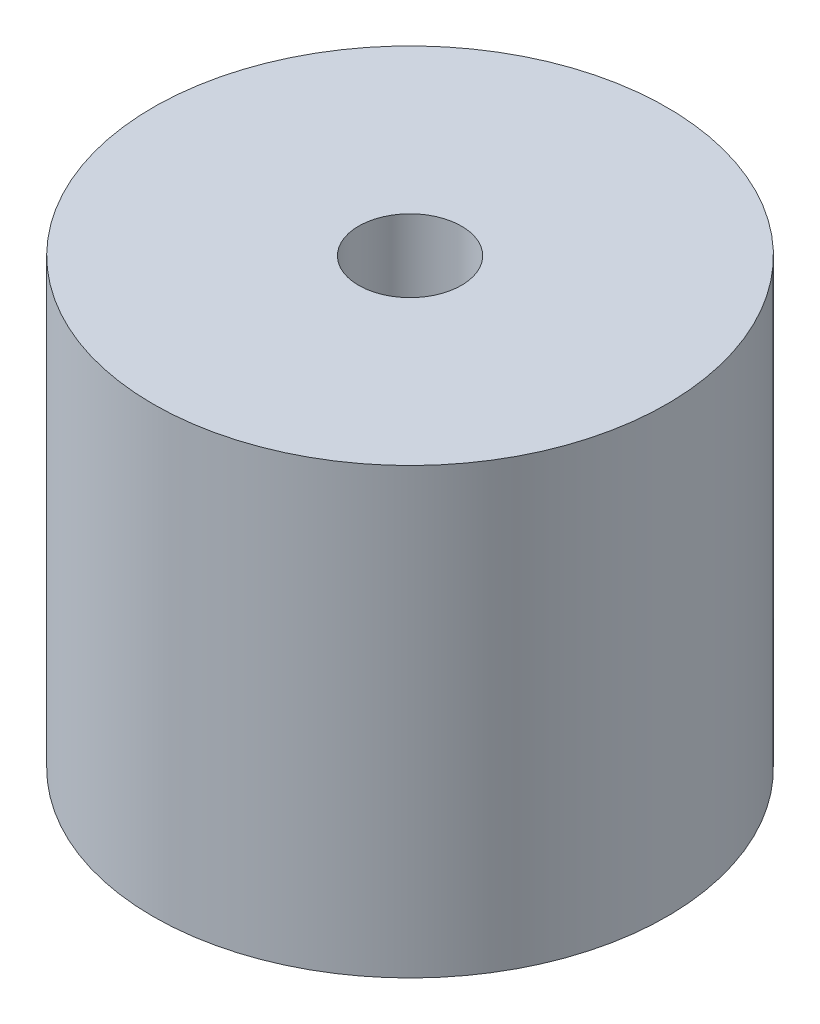
from build123d import *

# Parameters (mm, degrees)
SKETCH1_R           = 50
SKETCH1_R_2         = 10
BOSS_EXTRUDE1_DEPTH = 86.36


with BuildPart() as part:
    # Sketch1 → Boss-Extrude1 (new body)
    with BuildSketch(Plane(origin=(0, 0, 0), x_dir=(1, 0, 0), z_dir=(0, 1, 0))):
        Circle(SKETCH1_R)
        Circle(SKETCH1_R_2, mode=Mode.SUBTRACT)
    extrude(amount=BOSS_EXTRUDE1_DEPTH)


solid = part.part
